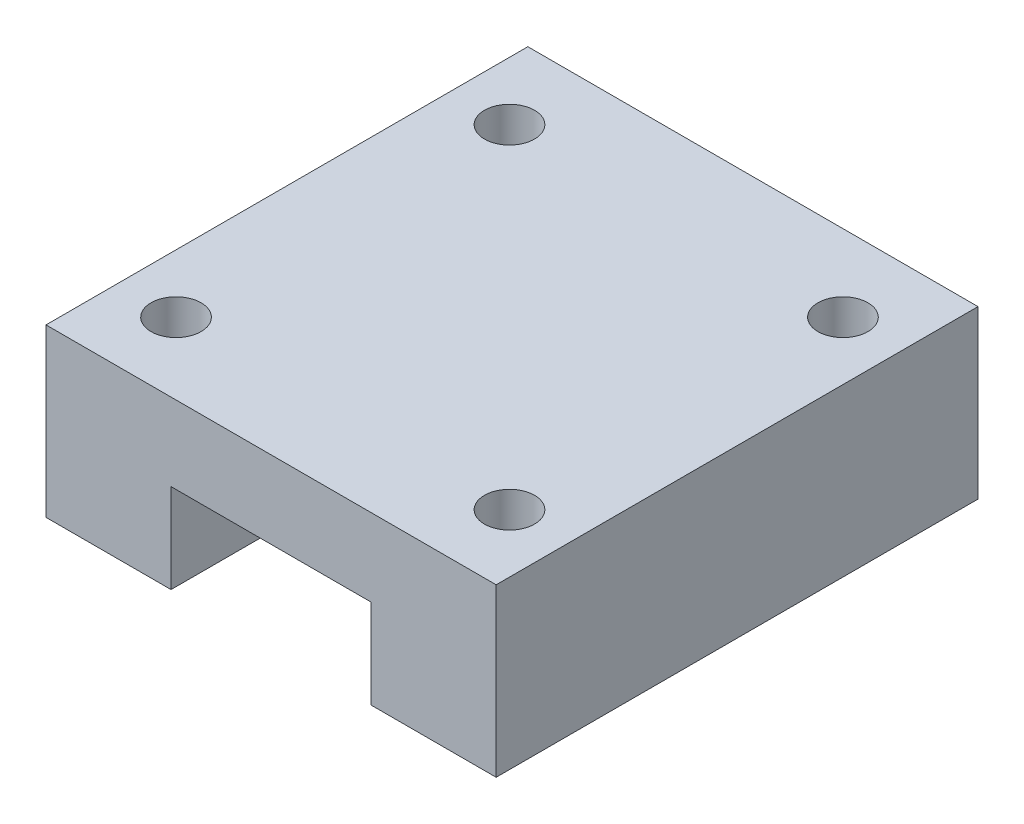
from build123d import *

# Parameters (mm, degrees)
SKETCH1_W                 = 27
SKETCH1_H                 = 28.9
BOSS_EXTRUDE1_DEPTH       = 10
SKETCH2_W                 = 12
SKETCH2_H                 = 5.35
CUT_EXTRUDE1_DEPTH        = 1
CUT_EXTRUDE1_DEPTH_BACK   = 29.9
F_3_0MM_DOWEL_HOLE1_D     = 3
F_3_0MM_DOWEL_HOLE1_DEPTH = 3
F_3_0MM_DOWEL_HOLE1_TIP   = 0.901290929


with BuildPart() as part:
    # Sketch1 → Boss-Extrude1 (new body)
    with BuildSketch(Plane(origin=(0, 0, 0), x_dir=(1, 0, 0), z_dir=(0, 1, 0))):
        with Locations((13.5, 14.45)):
            Rectangle(SKETCH1_W, SKETCH1_H)
    extrude(amount=BOSS_EXTRUDE1_DEPTH)

    # Sketch2 → Cut-Extrude1 (cut, two sides)
    with BuildSketch(Plane.XY) as cut_extrude1_sk:
        with Locations((13.5, 2.675)):
            Rectangle(SKETCH2_W, SKETCH2_H)
    extrude(amount=CUT_EXTRUDE1_DEPTH, mode=Mode.SUBTRACT)
    extrude(cut_extrude1_sk.sketch, amount=-CUT_EXTRUDE1_DEPTH_BACK, mode=Mode.SUBTRACT)

    # Ø3.0mm Dowel Hole1
    with Locations(Plane(origin=(0, 10, 0), x_dir=(1, 0, 0), z_dir=(0, 1, 0))):
        with Locations((3.5, 24.3), (23.5, 24.3), (3.5, 4.3), (23.5, 4.3)):
            Hole(F_3_0MM_DOWEL_HOLE1_D / 2, depth=F_3_0MM_DOWEL_HOLE1_DEPTH)
            with Locations((0, 0, -(F_3_0MM_DOWEL_HOLE1_DEPTH + F_3_0MM_DOWEL_HOLE1_TIP / 2))):  # 118° drill point
                Cone(0, F_3_0MM_DOWEL_HOLE1_D / 2, F_3_0MM_DOWEL_HOLE1_TIP, mode=Mode.SUBTRACT)


solid = part.part
